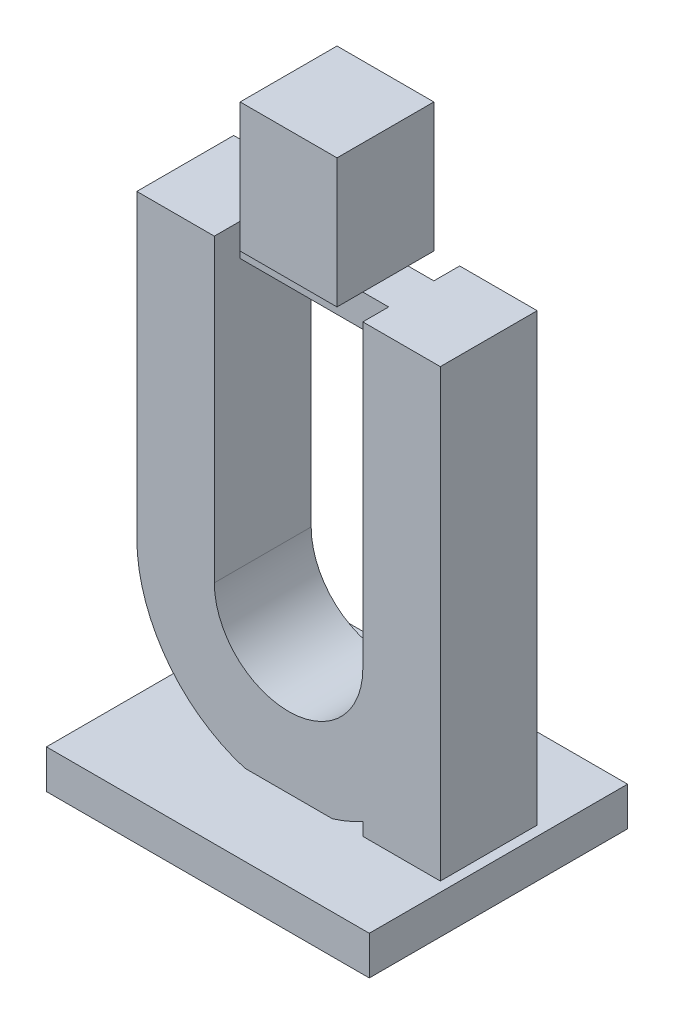
from build123d import *

# Parameters (mm, degrees)
AUFSATZ_LINEAR_AUSTRAGEN1_DEPTH      = 15
SKIZZE2_W                            = 50
SKIZZE2_H                            = 40
AUFSATZ_LINEAR_AUSTRAGEN2_DEPTH      = 5
AUFSATZ_LINEAR_AUSTRAGEN2_DEPTH_BACK = 1
SKIZZE3_W                            = 23
SKIZZE3_H                            = 7
AUFSATZ_LINEAR_AUSTRAGEN3_DEPTH      = 5
SKIZZE4_W                            = 15
SKIZZE4_H                            = 15
AUFSATZ_LINEAR_AUSTRAGEN4_DEPTH      = 20


with BuildPart() as part:
    # Skizze1 → Aufsatz-Linear austragen1 (new body)
    with BuildSketch(Plane.XY):
        with BuildLine():
            Line((0, 0), (0, 70))
            Line((0, 70), (-12, 70))
            Line((-12, 70), (-12, 23.5))
            ThreePointArc((-12, 23.5), (-23.5, 12), (-35, 23.5))
            Line((-35, 23.5), (-35, 70))
            Line((-35, 70), (-47, 70))
            Line((-47, 70), (-47, 23.5))
            ThreePointArc((-47, 23.5), (-35.374342087, 3.220700209), (-12, 3.006098468))
            Line((-12, 3.006098468), (-12, 0))
            Line((-12, 0), (0, 0))
        make_face()
    extrude(amount=AUFSATZ_LINEAR_AUSTRAGEN1_DEPTH)

    # Skizze2 → Aufsatz-Linear austragen2 (add, two sides)
    with BuildSketch(Plane.XZ) as aufsatz_linear_austragen2_sk:
        with Locations((-23.5, 7.5)):
            Rectangle(SKIZZE2_W, SKIZZE2_H)
    extrude(amount=AUFSATZ_LINEAR_AUSTRAGEN2_DEPTH)
    extrude(aufsatz_linear_austragen2_sk.sketch, amount=-AUFSATZ_LINEAR_AUSTRAGEN2_DEPTH_BACK)

    # Skizze3 → Aufsatz-Linear austragen3 (add)
    with BuildSketch(Plane(origin=(0, 70, 0), x_dir=(1, 0, 0), z_dir=(0, 1, 0))):
        with Locations((-23.5, -7.5)):
            Rectangle(SKIZZE3_W, SKIZZE3_H)
    extrude(amount=-AUFSATZ_LINEAR_AUSTRAGEN3_DEPTH)

    # Skizze4 → Aufsatz-Linear austragen4 (add)
    with BuildSketch(Plane(origin=(0, 70, 0), x_dir=(1, 0, 0), z_dir=(0, 1, 0))):
        with Locations((-23.5, -7.5)):
            Rectangle(SKIZZE4_W, SKIZZE4_H)
    extrude(amount=AUFSATZ_LINEAR_AUSTRAGEN4_DEPTH)


solid = part.part
